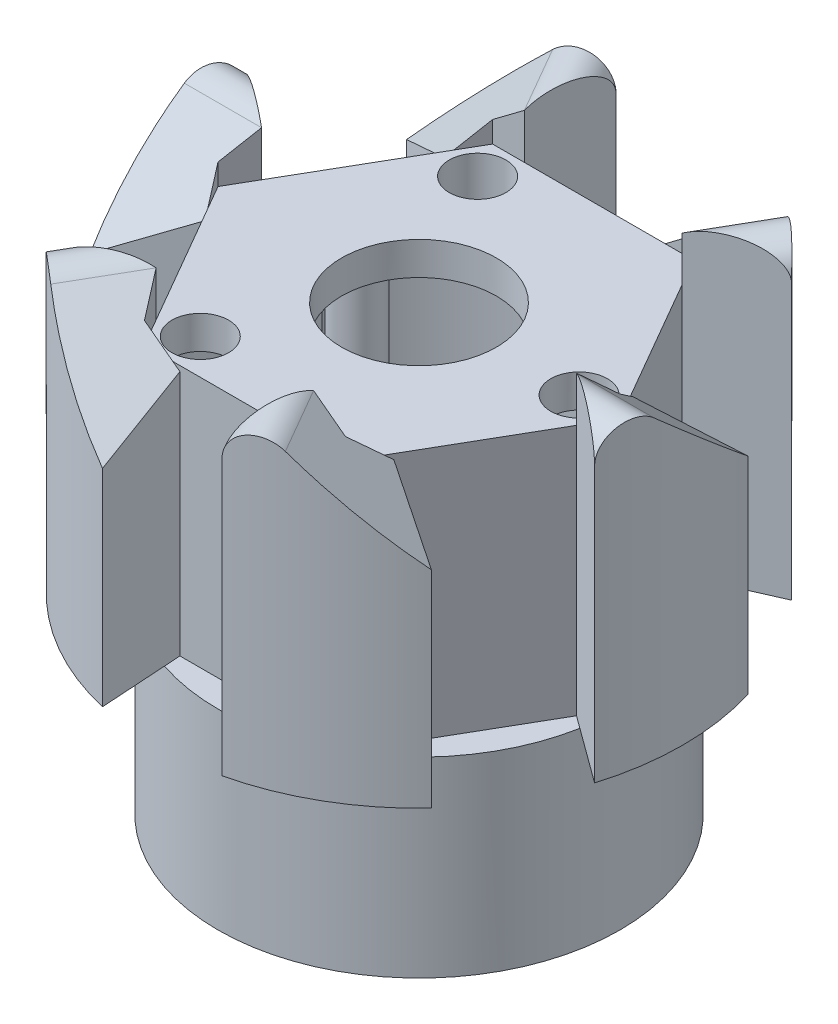
from build123d import *

# Parameters (mm, degrees)
SKETCH1_R               = 6.815
BOSS_EXTRUDE1_DEPTH     = 6.49
BOSS_EXTRUDE2_DEPTH     = 8.53
BOSS_EXTRUDE3_DEPTH     = 10
CIRPATTERN1_COUNT       = 6
SKETCH4_R               = 10.914422046
SKETCH4_R_2             = 8.94
CUT_EXTRUDE1_DEPTH      = 18
CUT_EXTRUDE2_DEPTH      = 18
CUT_EXTRUDE4_DEPTH      = 11.305565513
CIRPATTERN2_COUNT       = 6
SKETCH8_R               = 2.625
CUT_EXTRUDE5_DEPTH      = 2.775565513
CUT_EXTRUDE5_DEPTH_BACK = 16.02
SKETCH9_R               = 5.84
CUT_EXTRUDE6_DEPTH      = 13.9
BOSS_EXTRUDE4_DEPTH     = 13.9
CIRPATTERN3_COUNT       = 3
BOSS_EXTRUDE5_DEPTH     = 13.4
CIRPATTERN4_COUNT       = 3
SKETCH12_R              = 0.96
CUT_EXTRUDE7_DEPTH      = 3.25


with BuildPart() as part:
    # Sketch1 → Boss-Extrude1 (new body)
    with BuildSketch(Plane(origin=(0, 0, 0), x_dir=(1, 0, 0), z_dir=(0, 1, 0))):
        Circle(SKETCH1_R)
    extrude(amount=BOSS_EXTRUDE1_DEPTH)

    # Sketch2 → Boss-Extrude2 (add)
    with BuildSketch(Plane(origin=(0, 6.49, 0), x_dir=(1, 0, 0), z_dir=(0, 1, 0))):
        Polygon((3.4075, 5.901963127), (-3.4075, 5.901963127), (-6.815, 0), (-3.4075, -5.901963127), (3.4075, -5.901963127), (6.815, 0), align=None)
    extrude(amount=BOSS_EXTRUDE2_DEPTH)

    # Sketch3 → Boss-Extrude3 (add)
    with BuildSketch(Plane(origin=(0, 0, 0), x_dir=(0, 0, -1), z_dir=(1, 0, 0))):
        with BuildLine():
            Line((-2.6, 6.49), (2.6, 6.49))
            Line((2.6, 6.49), (2.6, 13.49))
            Line((2.6, 13.49), (-0.934676019, 16.550017775))
            ThreePointArc((-0.934676019, 16.550017775), (-2.011804271, 16.704512725), (-2.6, 15.789034847))
            Line((-2.6, 15.789034847), (-2.6, 13.49))
            Line((-2.6, 13.49), (-2.6, 6.49))
        make_face()
    boss_extrude3 = extrude(amount=BOSS_EXTRUDE3_DEPTH)

    # CirPattern1: Boss-Extrude3 ×6 about axis
    cirpattern1_axis = Axis((0, 0, 0), (0, 1, 0))
    for i in range(1, CIRPATTERN1_COUNT):
        add(boss_extrude3.rotate(cirpattern1_axis, i * 360 / CIRPATTERN1_COUNT))

    # Sketch4 → Cut-Extrude1 (cut)
    with BuildSketch(Plane(origin=(0, 0, 0), x_dir=(1, 0, 0), z_dir=(0, 1, 0))):
        Circle(SKETCH4_R)
        Circle(SKETCH4_R_2, mode=Mode.SUBTRACT)
    extrude(amount=CUT_EXTRUDE1_DEPTH, mode=Mode.SUBTRACT)

    # Sketch5 → Cut-Extrude2 (cut)
    with BuildSketch(Plane(origin=(0, 15.02, 0), x_dir=(1, 0, 0), z_dir=(0, 1, 0))):
        Polygon((-3.4075, 5.901963127), (-6.815, 0), (-3.4075, -5.901963127), (3.4075, -5.901963127), (6.815, 0), (3.4075, 5.901963127), align=None)
    extrude(amount=CUT_EXTRUDE2_DEPTH, mode=Mode.SUBTRACT)

    # Sketch7 → Cut-Extrude4 (cut, through all)
    with BuildSketch(Plane(origin=(0, 6.49, 0), x_dir=(1, 0, 0), z_dir=(0, 1, 0))):
        Polygon((-6.213841686, -1.041236743), (-8.553572353, -2.6), (-5.3138893, -2.6), align=None)
        Polygon((-8.553572353, 2.6), (-6.275364549, 0.934676019), (-5.3138893, 2.6), align=None)
    cut_extrude4 = extrude(amount=CUT_EXTRUDE4_DEPTH, mode=Mode.SUBTRACT)

    # CirPattern2: Cut-Extrude4 ×6 about axis
    cirpattern2_axis = Axis((0, 0, 0), (0, 1, 0))
    for i in range(1, CIRPATTERN2_COUNT):
        add(cut_extrude4.rotate(cirpattern2_axis, i * 360 / CIRPATTERN2_COUNT), mode=Mode.SUBTRACT)

    # Sketch8 → Cut-Extrude5 (cut, two sides)
    with BuildSketch(Plane(origin=(0, 15.02, 0), x_dir=(1, 0, 0), z_dir=(0, 1, 0))) as cut_extrude5_sk:
        Circle(SKETCH8_R)
    extrude(amount=CUT_EXTRUDE5_DEPTH, mode=Mode.SUBTRACT)
    extrude(cut_extrude5_sk.sketch, amount=-CUT_EXTRUDE5_DEPTH_BACK, mode=Mode.SUBTRACT)

    # Sketch9 → Cut-Extrude6 (cut)
    with BuildSketch(Plane(origin=(0, 0, 0), x_dir=(-1, 0, 0), z_dir=(0, -1, 0))):
        Circle(SKETCH9_R)
    extrude(amount=-CUT_EXTRUDE6_DEPTH, mode=Mode.SUBTRACT)

    # Sketch10 → Boss-Extrude4 (add)
    with BuildSketch(Plane(origin=(0, 0, 0), x_dir=(1, 0, 0), z_dir=(0, 1, 0))):
        with BuildLine():
            Line((-0.790866214, -5.84), (0.790866214, -5.84))
            ThreePointArc((0.790866214, -5.84), (0, -5.049133786), (-0.790866214, -5.84))
        make_face()
    boss_extrude4 = extrude(amount=BOSS_EXTRUDE4_DEPTH)

    # CirPattern3: Boss-Extrude4 ×3 about axis
    cirpattern3_axis = Axis((0, 0, 0), (0, 1, 0))
    for i in range(1, CIRPATTERN3_COUNT):
        add(boss_extrude4.rotate(cirpattern3_axis, i * 360 / CIRPATTERN3_COUNT))

    # Sketch11 → Boss-Extrude5 (add)
    with BuildSketch(Plane.XZ.offset(-13.9)):
        Polygon((1.104876589, 5.753522427), (0.982953313, 5.335499767), (1.686743969, 5.130227492), (1.811594174, 5.558285339), align=None)
    boss_extrude5 = extrude(amount=BOSS_EXTRUDE5_DEPTH)

    # CirPattern4: Boss-Extrude5 ×3 about axis
    cirpattern4_axis = Axis((0, 0, 0), (0, 1, 0))
    for i in range(1, CIRPATTERN4_COUNT):
        add(boss_extrude5.rotate(cirpattern4_axis, i * 360 / CIRPATTERN4_COUNT))

    # Sketch12 → Cut-Extrude7 (cut)
    with BuildSketch(Plane(origin=(0, 15.02, 0), x_dir=(1, 0, 0), z_dir=(0, 1, 0))):
        with Locations((-2.714264925, -4.702681498)):
            Circle(SKETCH12_R)
        with Locations((-2.714679677, 4.701963127)):
            Circle(SKETCH12_R)
        with Locations((5.429359354, 0)):
            Circle(SKETCH12_R)
    extrude(amount=-CUT_EXTRUDE7_DEPTH, mode=Mode.SUBTRACT)


solid = part.part
